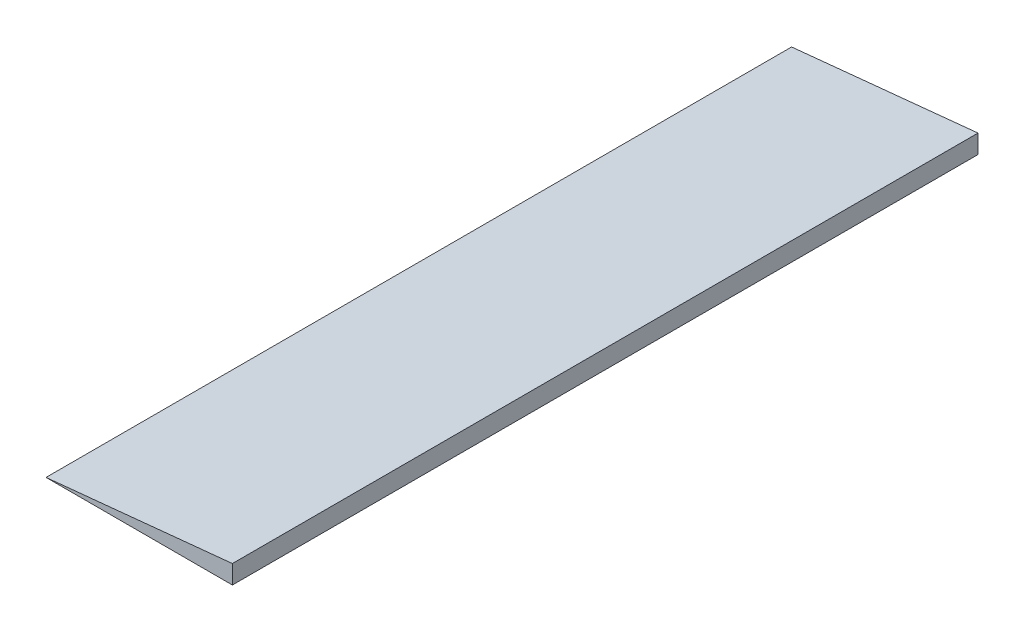
from build123d import *

# Parameters (mm, degrees)
SKETCH1_W           = 1000
SKETCH1_H           = 4000
BOSS_EXTRUDE1_DEPTH = 100
CUT_EXTRUDE1_DEPTH  = 5046


with BuildPart() as part:
    # Sketch1 → Boss-Extrude1 (new body)
    with BuildSketch(Plane(origin=(0, 0, 0), x_dir=(1, 0, 0), z_dir=(0, 1, 0))):
        with Locations((500, 2000)):
            Rectangle(SKETCH1_W, SKETCH1_H)
    extrude(amount=BOSS_EXTRUDE1_DEPTH)

    # Sketch2 → Cut-Extrude1 (cut)
    with BuildSketch(Plane.XY):
        Polygon((0, 0), (1000, 100), (0, 100), align=None)
    extrude(amount=-CUT_EXTRUDE1_DEPTH, mode=Mode.SUBTRACT)


solid = part.part
